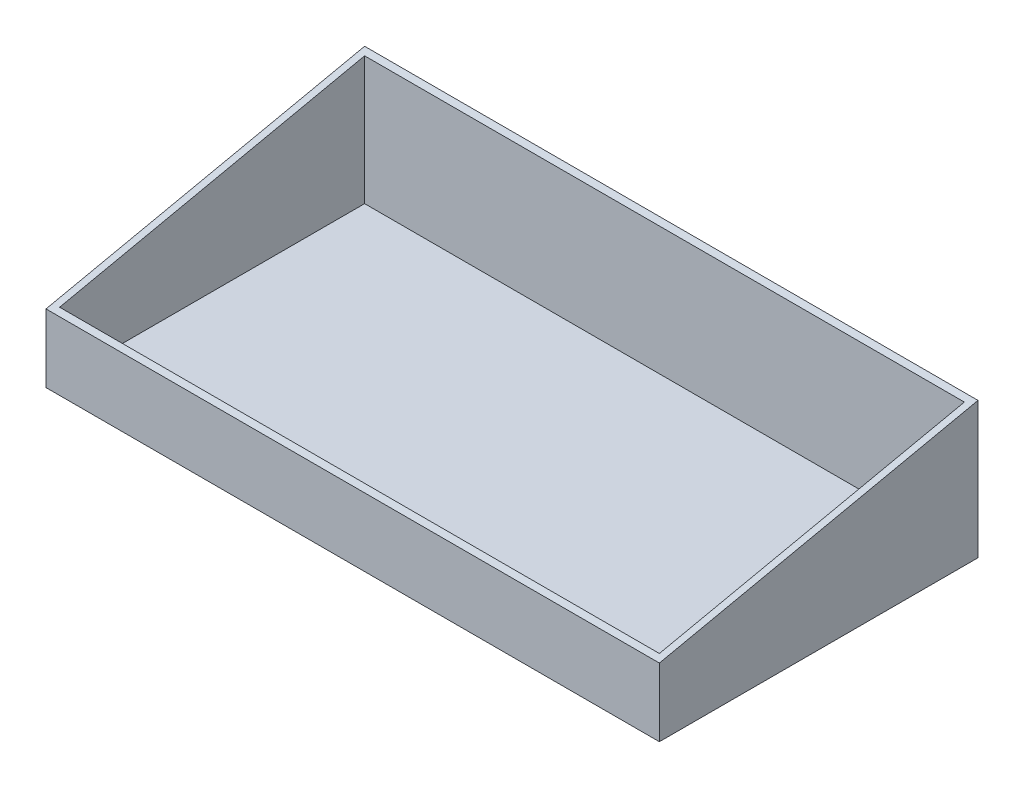
from build123d import *

# Parameters (mm, degrees)
CROQUIS1_W              = 360
CROQUIS1_H              = 187
SALIENTE_EXTRUIR1_DEPTH = 80
VACIADO1_T              = -4
CORTAR_EXTRUIR1_DEPTH   = 361


with BuildPart() as part:
    # Croquis1 → Saliente-Extruir1 (new body)
    with BuildSketch(Plane(origin=(0, 0, 0), x_dir=(1, 0, 0), z_dir=(0, 1, 0))):
        Rectangle(CROQUIS1_W, CROQUIS1_H)
    extrude(amount=SALIENTE_EXTRUIR1_DEPTH)

    # Vaciado1
    vaciado1_openings = [part.faces().sort_by_distance(p)[0] for p in [
        (0, 80, 0),
    ]]
    offset(amount=VACIADO1_T, openings=vaciado1_openings, kind=Kind.INTERSECTION)

    # Croquis2 → Cortar-Extruir1 (cut, through all)
    with BuildSketch(Plane.ZY.offset(180)):
        Polygon((-93.5, 80), (93.5, 40), (93.5, 80), align=None)
    extrude(amount=-CORTAR_EXTRUIR1_DEPTH, mode=Mode.SUBTRACT)


solid = part.part
